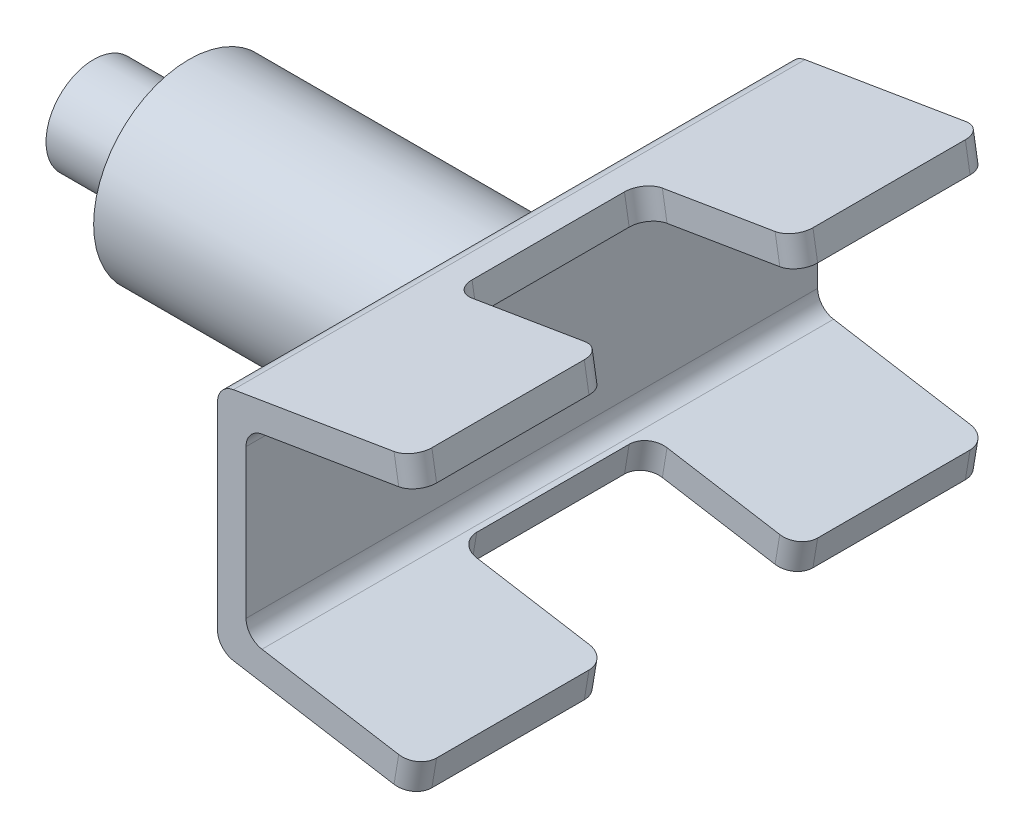
from build123d import *

# Parameters (mm, degrees)
SKETCH1_R           = 127
BOSS_EXTRUDE1_DEPTH = 63.5
BOSS_EXTRUDE2_DEPTH = 381
CUT_EXTRUDE1_DEPTH  = 203.2
CUT_EXTRUDE2_DEPTH  = 203.2
FILLET1_R           = 25.4
FILLET2_R           = 25.4
FILLET3_R           = 25.4
SKETCH5_R           = 127
BOSS_EXTRUDE3_DEPTH = 304.8
SKETCH6_R           = 63.5
BOSS_EXTRUDE4_DEPTH = 127


with BuildPart() as part:
    # Sketch1 → Boss-Extrude1 (new body, symmetric)
    with BuildSketch(Plane(origin=(0, 0, 0), x_dir=(0, 0, -1), z_dir=(1, 0, 0))):
        Circle(SKETCH1_R)
    extrude(amount=BOSS_EXTRUDE1_DEPTH, both=True)

    # Sketch2 → Boss-Extrude2 (add, symmetric)
    with BuildSketch(Plane.XY):
        Polygon((88.9, -120.65), (88.9, 120.65), (317.5, 158.75), (311.236398584, 196.331608498), (50.8, 152.925542067), (50.8, -152.925542067), (311.236398584, -196.331608498), (317.5, -158.75), align=None)
    extrude(amount=BOSS_EXTRUDE2_DEPTH, both=True)

    # Sketch3 → Cut-Extrude1 (cut)
    with BuildSketch(Plane(origin=(334.662162162, 55.777027027, 0), x_dir=(0, 0, -1), z_dir=(0.986393924, 0.164398987, 0))):
        Polygon((0, 104.393356939), (-127, 104.393356939), (-127, 142.493356939), (127, 142.493356939), (127, 104.393356939), align=None)
    extrude(amount=-CUT_EXTRUDE1_DEPTH, mode=Mode.SUBTRACT)

    # Sketch4 → Cut-Extrude2 (cut)
    with BuildSketch(Plane(origin=(334.662162162, -55.777027027, 0), x_dir=(0, 0, -1), z_dir=(0.986393924, -0.164398987, 0))):
        Polygon((0, -142.493356939), (-127, -142.493356939), (-127, -104.393356939), (127, -104.393356939), (127, -142.493356939), align=None)
    extrude(amount=-CUT_EXTRUDE2_DEPTH, mode=Mode.SUBTRACT)

    # Fillet1
    fillet1_edges = [part.edges().sort_by_distance(p)[0] for p in [
        (88.9, -120.65, 0),
        (88.9, 120.65, 0),
    ]]
    fillet(fillet1_edges, radius=FILLET1_R)

    # Fillet2
    fillet2_edges = [part.edges().sort_by_distance(p)[0] for p in [
        (50.8, 152.925542067, 0),
        (50.8, -152.925542067, 0),
    ]]
    fillet(fillet2_edges, radius=FILLET2_R)

    # Fillet3
    fillet3_edges = [part.edges().sort_by_distance(p)[0] for p in [
        (314.368199292, -177.540804249, 381),
        (113.932953969, 144.134930029, 127),
        (113.932953969, 144.134930029, -127),
        (314.368199292, 177.540804249, -127),
        (314.368199292, 177.540804249, 127),
        (113.932953969, -144.134930029, 127),
        (113.932953969, -144.134930029, -127),
        (314.368199292, -177.540804249, -127),
        (314.368199292, -177.540804249, 127),
        (314.368199292, 177.540804249, -381),
        (314.368199292, -177.540804249, -381),
        (314.368199292, 177.540804249, 381),
    ]]
    fillet(fillet3_edges, radius=FILLET3_R)

    # Sketch5 → Boss-Extrude3 (add)
    with BuildSketch(Plane.ZY.offset(63.5)):
        Circle(SKETCH5_R)
    extrude(amount=BOSS_EXTRUDE3_DEPTH)

    # Sketch6 → Boss-Extrude4 (add)
    with BuildSketch(Plane.ZY.offset(368.3)):
        Circle(SKETCH6_R)
    extrude(amount=BOSS_EXTRUDE4_DEPTH)


solid = part.part
